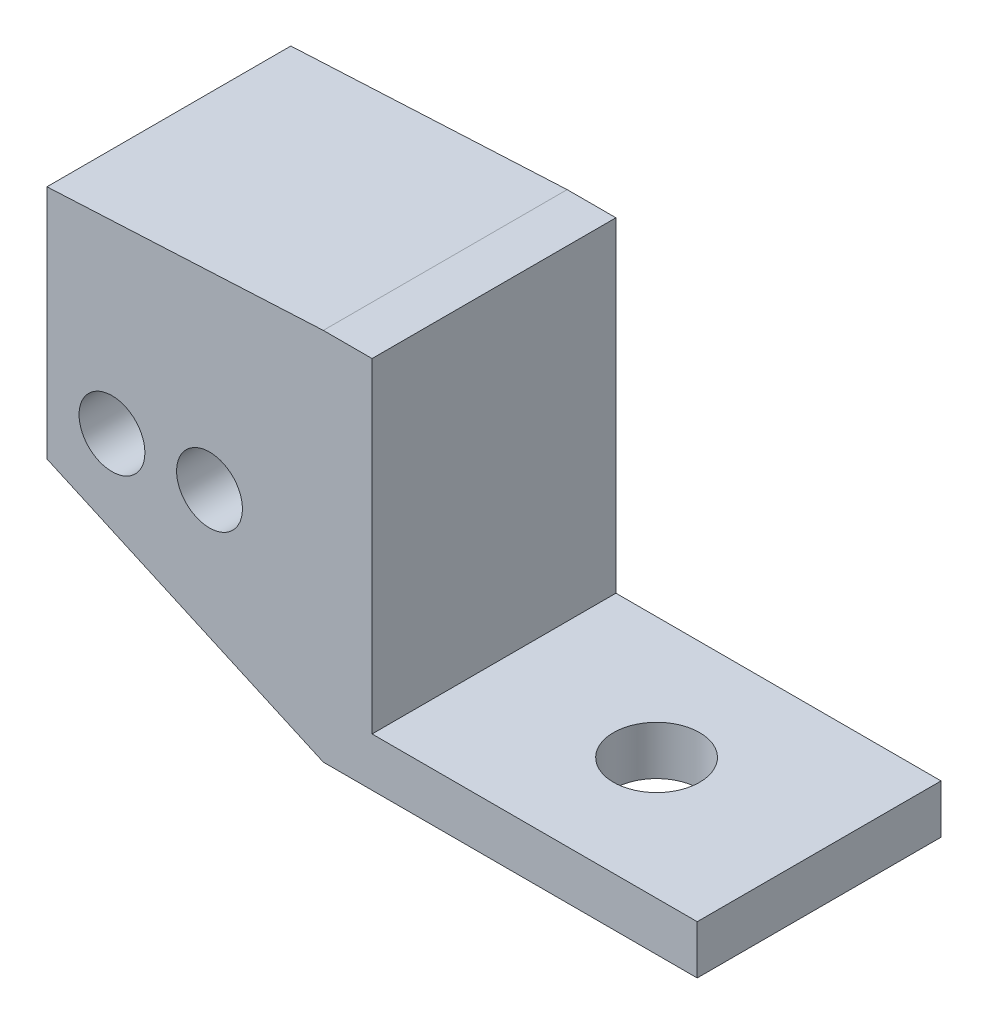
from build123d import *

# Parameters (mm, degrees)
SKETCH1_R           = 3.025
SKETCH1_R_2         = 2.025
BOSS_EXTRUDE1_DEPTH = 15
BOSS_EXTRUDE2_START = 6
SKETCH1_2_R         = 3.025
BOSS_EXTRUDE2_DEPTH = 9
SKETCH2_R           = 2.65
CUT_EXTRUDE1_DEPTH  = 3


with BuildPart() as part:
    # Sketch1 → Boss-Extrude1 (new body)
    with BuildSketch(Plane.XY):
        Polygon((66.489922843, -72.31585339), (69.489922843, -72.31585339), (69.489922843, -92.31585339), (89.489922843, -92.31585339), (89.489922843, -95.31585339), (66.489922843, -95.31585339), (49.489922843, -87.66585339), (49.489922843, -73.16585339), align=None)
        with Locations((56.489922843, -77.31585339)):
            Circle(SKETCH1_R, mode=Mode.SUBTRACT)
        with Locations((53.489922843, -84.31585339)):
            Circle(SKETCH1_R_2, mode=Mode.SUBTRACT)
        with Locations((59.489922843, -84.31585339)):
            Circle(SKETCH1_R_2, mode=Mode.SUBTRACT)
    extrude(amount=BOSS_EXTRUDE1_DEPTH)

    # Sketch1_2 → Boss-Extrude2 (add)
    with BuildSketch(Plane.XY.offset(BOSS_EXTRUDE2_START)):
        with Locations((56.489922843, -77.31585339)):
            Circle(SKETCH1_2_R)
    extrude(amount=BOSS_EXTRUDE2_DEPTH)

    # Sketch2 → Cut-Extrude1 (cut)
    with BuildSketch(Plane.XZ.offset(95.31585339)):
        with Locations((79.489922843, 7.5)):
            Circle(SKETCH2_R)
    extrude(amount=-CUT_EXTRUDE1_DEPTH, mode=Mode.SUBTRACT)


solid = part.part
